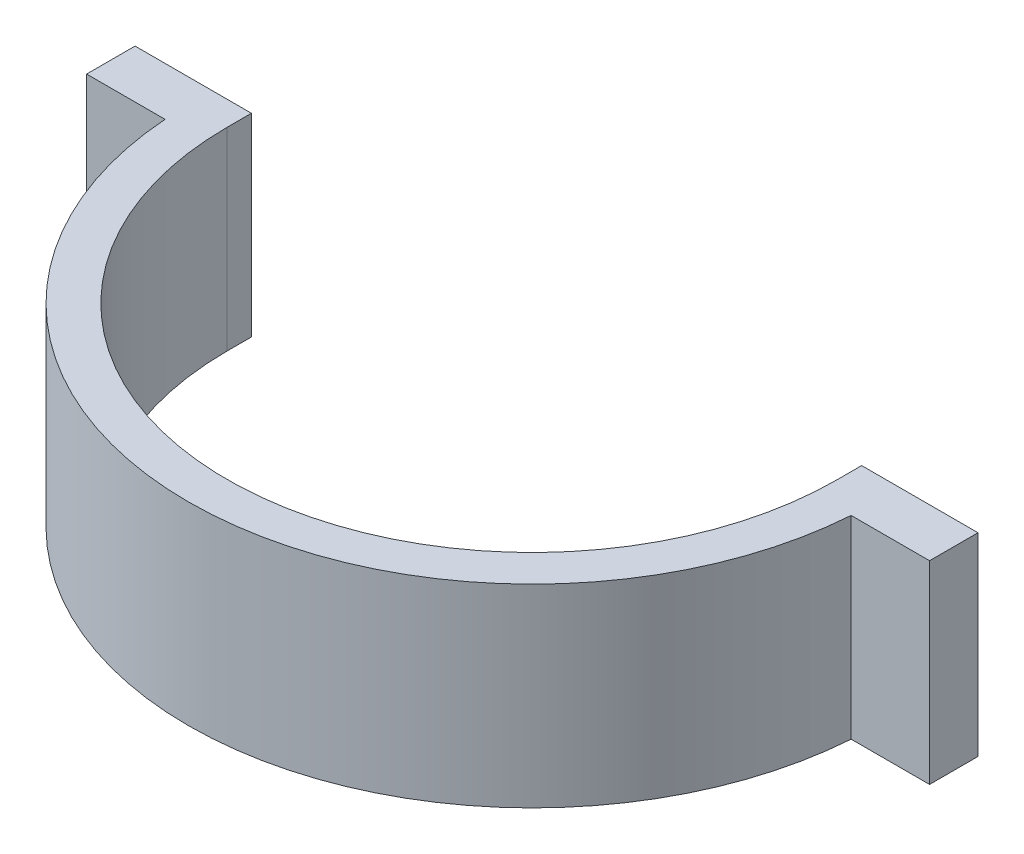
from build123d import *

# Parameters (mm, degrees)
SKETCH2_R           = 45.0723
SKETCH2_R_2         = 39.9923
BOSS_EXTRUDE1_DEPTH = 25.4
SKETCH3_W           = 90.1446
SKETCH3_H           = 25.4
CUT_EXTRUDE1_DEPTH  = 46.0723
BOSS_EXTRUDE2_DEPTH = 3.175


with BuildPart() as part:
    # Sketch2 → Boss-Extrude1 (new body)
    with BuildSketch(Plane(origin=(0, 0, 0), x_dir=(1, 0, 0), z_dir=(0, 1, 0))):
        Circle(SKETCH2_R)
        Circle(SKETCH2_R_2, mode=Mode.SUBTRACT)
    extrude(amount=BOSS_EXTRUDE1_DEPTH)

    # Sketch3 → Cut-Extrude1 (cut, through all)
    with BuildSketch(Plane.XY):
        with Locations((0, 12.7)):
            Rectangle(SKETCH3_W, SKETCH3_H)
    extrude(amount=-CUT_EXTRUDE1_DEPTH, mode=Mode.SUBTRACT)

    # Sketch5 → Boss-Extrude2 (add, symmetric)
    with BuildSketch(Plane(origin=(0, 0, 0), x_dir=(-1, 0, 0), z_dir=(0, 0, -1))):
        Polygon((-45.081415665, 25.4), (-39.9923, 25.4), (-39.9923, 0), (-45.167196058, 0), (-55.241415665, 0), (-55.241415665, 25.4), align=None)
        Polygon((45.081415665, 25.4), (55.241415665, 25.4), (55.241415665, 0), (45.167196058, 0), (39.9923, 0), (39.9923, 25.4), align=None)
    extrude(amount=BOSS_EXTRUDE2_DEPTH, both=True)


solid = part.part
